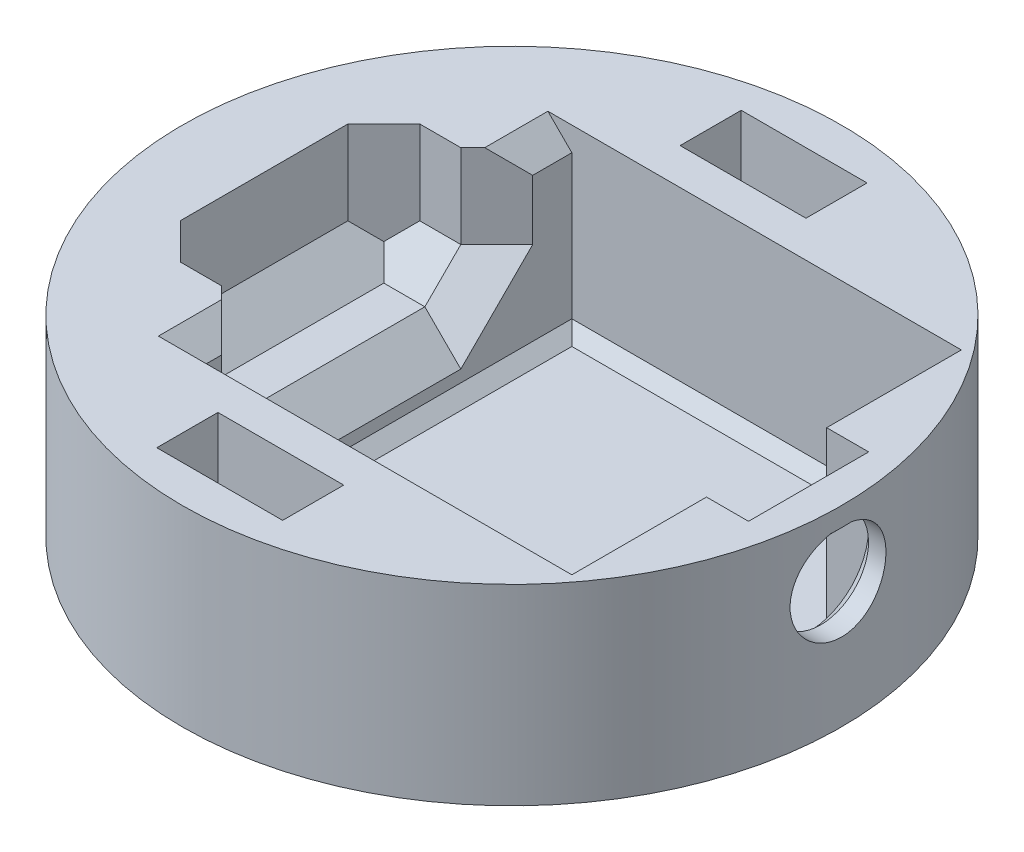
from build123d import *

# Parameters (mm, degrees)
SKETCH1_R           = 27.5
BOSS_EXTRUDE1_DEPTH = 16
CUT_EXTRUDE1_DEPTH  = 15
CUT_EXTRUDE2_DEPTH  = 15
SKETCH6_W           = 18.849176954
SKETCH6_H           = 19.96776686
CUT_EXTRUDE4_DEPTH  = 10
CHAMFER2_SIZE       = 3
CHAMFER3_SIZE       = 3
SKETCH8_W           = 7.009579852
SKETCH8_H           = 10.026822324
CUT_EXTRUDE5_DEPTH  = 15
CHAMFER4_SIZE       = 1
CHAMFER5_SIZE       = 2
CHAMFER6_SIZE       = 2
CHAMFER7_SIZE       = 1
CHAMFER8_SIZE       = 0.5
SKETCH9_W           = 10.5
SKETCH9_H           = 5.1
CUT_EXTRUDE6_DEPTH  = 5.5


with BuildPart() as part:
    # Sketch1 → Boss-Extrude1 (new body)
    with BuildSketch(Plane(origin=(0, 0, 0), x_dir=(1, 0, 0), z_dir=(0, 1, 0))):
        Circle(SKETCH1_R)
    extrude(amount=BOSS_EXTRUDE1_DEPTH)

    # Sketch3 → Cut-Extrude1 (cut)
    with BuildSketch(Plane(origin=(0, 16, 0), x_dir=(1, 0, 0), z_dir=(0, 1, 0))):
        Polygon((-11.25, -16.25), (16.25, -16.25), (21.25, -16.25), (21.25, 16.25), (16.25, 16.25), (-11.25, 16.25), align=None)
    extrude(amount=-CUT_EXTRUDE1_DEPTH, mode=Mode.SUBTRACT)

    # Sketch4 → Cut-Extrude2 (cut)
    with BuildSketch(Plane.ZY.offset(-21.25)):
        with BuildLine():
            Line((-2.103243144, 13.902406248), (2.103243144, 13.902406248))
            ThreePointArc((2.103243144, 13.902406248), (0, 6.5), (-2.103243144, 13.902406248))
        make_face()
    extrude(amount=-CUT_EXTRUDE2_DEPTH, mode=Mode.SUBTRACT)

    # Sketch6 → Cut-Extrude4 (cut)
    with BuildSketch(Plane(origin=(0, 16, 0), x_dir=(1, 0, 0), z_dir=(0, 1, 0))):
        with Locations((-11.25, 0)):
            Rectangle(SKETCH6_W, SKETCH6_H)
    extrude(amount=-CUT_EXTRUDE4_DEPTH, mode=Mode.SUBTRACT)

    # Chamfer2
    chamfer2_edges = [part.edges().sort_by_distance(p)[0] for p in [
        (-11.25, 6, 0),
        (-11.25, 11, -9.98388343),
        (-11.25, 11, 9.98388343),
        (-15.962294239, 6, 9.98388343),
        (-15.962294239, 6, -9.98388343),
        (-20.674588477, 6, 0),
    ]]
    chamfer(chamfer2_edges, length=CHAMFER2_SIZE)

    # Chamfer3
    chamfer3_edges = [part.edges().sort_by_distance(p)[0] for p in [
        (-20.674588477, 12.5, 9.98388343),
        (-20.674588477, 12.5, -9.98388343),
    ]]
    chamfer(chamfer3_edges, length=CHAMFER3_SIZE)

    # Sketch8 → Cut-Extrude5 (cut)
    with BuildSketch(Plane(origin=(0, 16, 0), x_dir=(1, 0, 0), z_dir=(0, 1, 0))):
        with Locations((21.25, 0)):
            Rectangle(SKETCH8_W, SKETCH8_H)
    extrude(amount=-CUT_EXTRUDE5_DEPTH, mode=Mode.SUBTRACT)

    # Chamfer4
    chamfer4_edges = [part.edges().sort_by_distance(p)[0] for p in [
        (24.754789926, 6.5, 0),
        (24.754789926, 13.902406248, 0),
    ]]
    chamfer(chamfer4_edges, length=CHAMFER4_SIZE)

    # Chamfer5
    chamfer5_edges = [part.edges().sort_by_distance(p)[0] for p in [
        (24.754789926, 1, 0),
    ]]
    chamfer(chamfer5_edges, length=CHAMFER5_SIZE)

    # Chamfer6
    chamfer6_edges = [part.edges().sort_by_distance(p)[0] for p in [
        (-11.25, 16, -14.616941715),
        (-11.25, 16, 14.616941715),
    ]]
    chamfer(chamfer6_edges, length=CHAMFER6_SIZE)

    # Chamfer7
    chamfer7_edges = [part.edges().sort_by_distance(p)[0] for p in [
        (22.002394963, 1, 5.013411162),
        (22.002394963, 1, -5.013411162),
        (5, 1, -16.25),
        (21.25, 1, 10.631705581),
        (5, 1, 16.25),
        (-11.25, 1, 0),
        (21.25, 1, -10.631705581),
    ]]
    chamfer(chamfer7_edges, length=CHAMFER7_SIZE)

    # Chamfer8
    chamfer8_edges = [part.edges().sort_by_distance(p)[0] for p in [
        (27.479855714, 13.902406248, 1.05239247),
    ]]
    chamfer(chamfer8_edges, length=CHAMFER8_SIZE)

    # Sketch9 → Cut-Extrude6 (cut)
    with BuildSketch(Plane(origin=(0, 16, 0), x_dir=(1, 0, 0), z_dir=(0, 1, 0))):
        with Locations((0, 21.833387082)):
            Rectangle(SKETCH9_W, SKETCH9_H)
        with Locations((0, -21.833387082)):
            Rectangle(SKETCH9_W, SKETCH9_H)
    extrude(amount=-CUT_EXTRUDE6_DEPTH, mode=Mode.SUBTRACT)


solid = part.part
